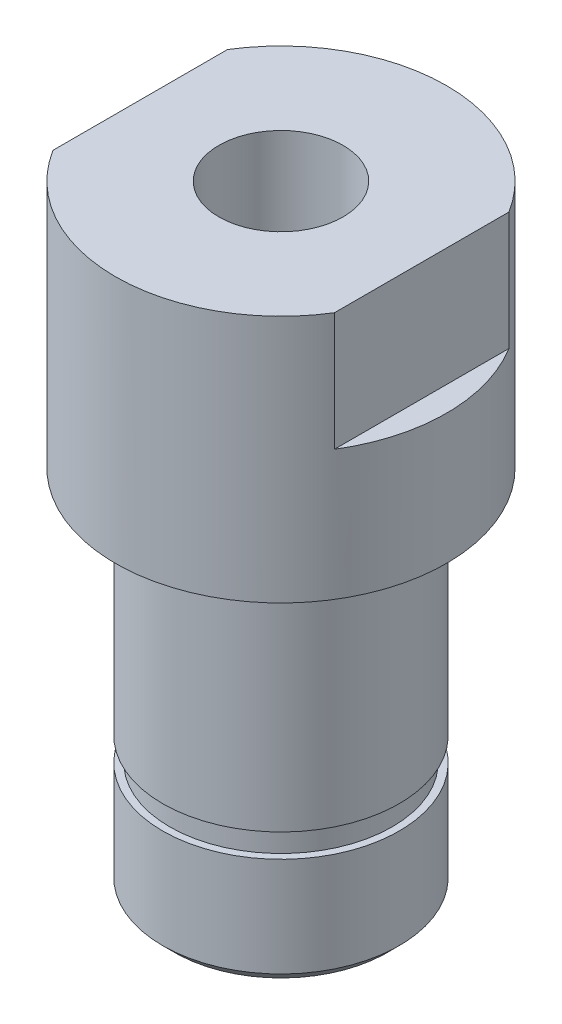
from build123d import *

# Parameters (mm, degrees)
SKETCH1_R                        = 14
BOSS_EXTRUDE1_DEPTH              = 6
SKETCH2_R                        = 14
BOSS_EXTRUDE2_DEPTH              = 15
SKETCH3_R                        = 10
BOSS_EXTRUDE3_DEPTH              = 31
F_10_5_10_5_DIAMETER_HOLE1_D     = 10.5
F_10_5_10_5_DIAMETER_HOLE1_DEPTH = 22
F_10_5_10_5_DIAMETER_HOLE1_TIP   = 3.15451825
CHAMFER1_SIZE                    = 1
SKETCH5_W                        = 6.241360462
SKETCH5_H                        = 33.57083513
SKETCH5_W_2                      = 3.803761641
CUT_EXTRUDE2_DEPTH               = 10
SKETCH6_W                        = 1.2
SKETCH6_H                        = 2


with BuildPart() as part:
    # Sketch1 → Boss-Extrude1 (new body)
    with BuildSketch(Plane(origin=(0, 0, 0), x_dir=(1, 0, 0), z_dir=(0, 1, 0))):
        Circle(SKETCH1_R)
    extrude(amount=BOSS_EXTRUDE1_DEPTH)

    # Sketch2 → Boss-Extrude2 (add)
    with BuildSketch(Plane.XZ):
        Circle(SKETCH2_R)
    extrude(amount=BOSS_EXTRUDE2_DEPTH)

    # Sketch3 → Boss-Extrude3 (add)
    with BuildSketch(Plane.XZ.offset(15)):
        Circle(SKETCH3_R)
    extrude(amount=BOSS_EXTRUDE3_DEPTH)

    # Ø10.5 (10.5) Diameter Hole1
    with Locations(Plane.ZX.offset(6)):
        with Locations((0, 0)):
            Hole(F_10_5_10_5_DIAMETER_HOLE1_D / 2, depth=F_10_5_10_5_DIAMETER_HOLE1_DEPTH)
            with Locations((0, 0, -(F_10_5_10_5_DIAMETER_HOLE1_DEPTH + F_10_5_10_5_DIAMETER_HOLE1_TIP / 2))):  # 118° drill point
                Cone(0, F_10_5_10_5_DIAMETER_HOLE1_D / 2, F_10_5_10_5_DIAMETER_HOLE1_TIP, mode=Mode.SUBTRACT)

    # Chamfer1
    chamfer1_edges = [part.edges().sort_by_distance(p)[0] for p in [
        (-10, -46, 0),
    ]]
    chamfer(chamfer1_edges, length=CHAMFER1_SIZE)

    # Sketch5 → Cut-Extrude2 (cut)
    with BuildSketch(Plane(origin=(0, 6, 0), x_dir=(1, 0, 0), z_dir=(0, 1, 0))):
        with Locations((-15.020680231, 0)):
            Rectangle(SKETCH5_W, SKETCH5_H)
        with Locations((13.801880821, 0)):
            Rectangle(SKETCH5_W_2, SKETCH5_H)
    extrude(amount=-CUT_EXTRUDE2_DEPTH, mode=Mode.SUBTRACT)

    # Sketch6 → Cut-Revolve1 (revolve, cut)
    with BuildSketch(Plane(origin=(0, 0, 0), x_dir=(0, 0, -1), z_dir=(1, 0, 0))):
        with Locations((-10, -35.6)):
            Rectangle(SKETCH6_W, SKETCH6_H)
    revolve(axis=Axis((0, -46, 0), (0, 1, 0)), mode=Mode.SUBTRACT)


solid = part.part
